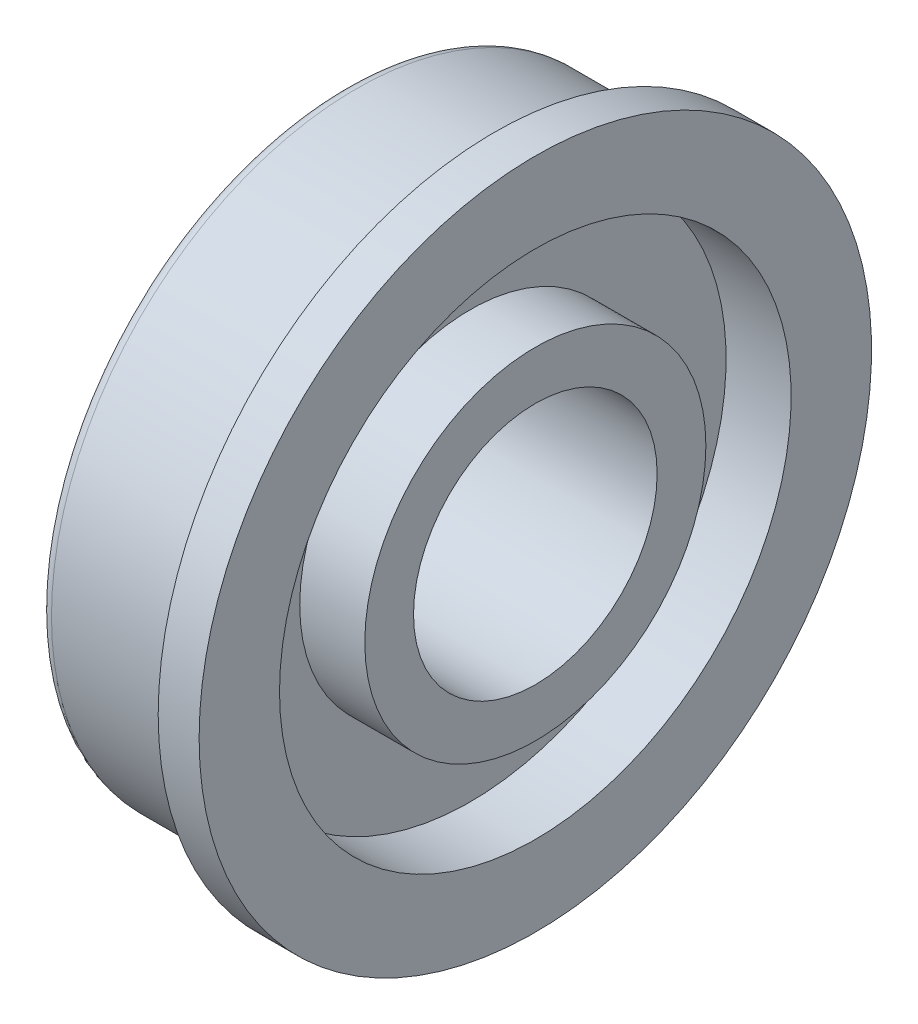
from build123d import *


with BuildPart() as part:
    # Sketch3 → bearing-revolution (revolve)
    with BuildSketch(Plane.XY):
        with BuildLine():
            Line((0.3048, 3.175), (4.9784, 3.175))
            Line((4.9784, 3.175), (4.9784, 4.445))
            Line((4.9784, 4.445), (3.28295, 4.445))
            Line((3.28295, 4.445), (3.28295, 6.6675))
            Line((3.28295, 6.6675), (4.9784, 6.6675))
            Line((4.9784, 6.6675), (4.9784, 8.763))
            Line((4.9784, 8.763), (3.9116, 8.763))
            Line((3.9116, 8.763), (3.9116, 7.9375))
            Line((3.9116, 7.9375), (0.3048, 7.9375))
            ThreePointArc((0.3048, 7.9375), (0.089273853, 7.848226147), (0, 7.6327))
            Line((0, 7.6327), (0, 6.6675))
            Line((0, 6.6675), (1.69545, 6.6675))
            Line((1.69545, 6.6675), (1.69545, 4.445))
            Line((1.69545, 4.445), (0, 4.445))
            Line((0, 4.445), (0, 3.4798))
            ThreePointArc((0, 3.4798), (0.089273853, 3.264273853), (0.3048, 3.175))
        make_face()
    revolve(axis=Axis((-4.832058368, 0, 0), (1, 0, 0)))


solid = part.part
